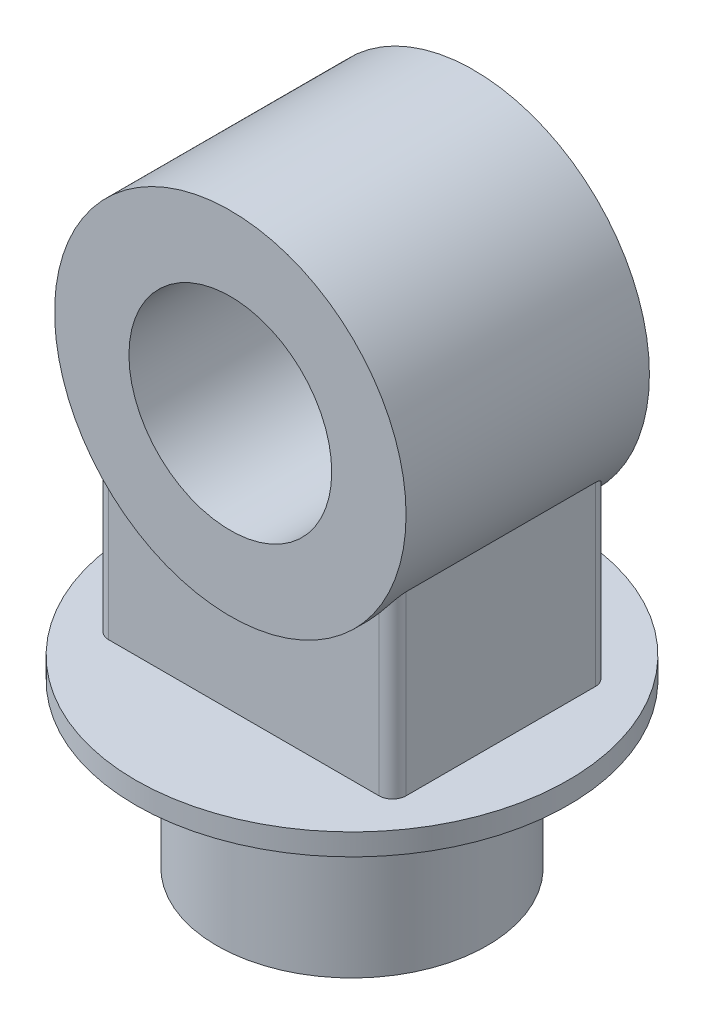
from build123d import *

# Parameters (mm, degrees)
SKETCH2_R                = 100
BOSS_EXTRUDE1_DEPTH      = 120
SKETCH3_R                = 160
BOSS_EXTRUDE2_DEPTH      = 16
SKETCH4_R                = 130
SKETCH4_R_2              = 75
BOSS_EXTRUDE7_DEPTH      = 90
BOSS_EXTRUDE8_REACH      = 402.125
BOSS_EXTRUDE8_END_RADIUS = 130
SKETCH6_W                = 220
SKETCH6_H                = 160
FILLET1_R                = 10


with BuildPart() as part:
    # Sketch2 → Boss-Extrude1 (new body)
    with BuildSketch(Plane(origin=(0, 0, 0), x_dir=(1, 0, 0), z_dir=(0, 1, 0))):
        with Locations(Location((0, 0, 0), (0, 0, 270))):
            Circle(SKETCH2_R)
    extrude(amount=BOSS_EXTRUDE1_DEPTH)

    # Sketch3 → Boss-Extrude2 (add)
    with BuildSketch(Plane(origin=(0, 120, 0), x_dir=(1, 0, 0), z_dir=(0, 1, 0))):
        with Locations(Location((0, 0, 0), (0, 0, 270))):
            Circle(SKETCH3_R)
    extrude(amount=BOSS_EXTRUDE2_DEPTH)



with BuildPart() as body_2:
    # Sketch4 → Boss-Extrude7 (new, symmetric)
    with BuildSketch(Plane.XY):
        with Locations(Location((0, 336, 0), (0, 0, 180))):
            Circle(SKETCH4_R)
        with Locations(Location((0, 336, 0), (0, 0, 180))):
            Circle(SKETCH4_R_2, mode=Mode.SUBTRACT)
    extrude(amount=BOSS_EXTRUDE7_DEPTH, both=True)


with BuildPart() as part_1:
    add(part.part)

    add(body_2.part)  # Boss-Extrude8 merges body 2
    # Boss-Extrude8: up to this cylinder (the profile starts outside it)
    boss_extrude8_end = Plane(origin=(0, 336, 0), z_dir=(0, 0, -1)) * Cylinder(BOSS_EXTRUDE8_END_RADIUS, 1065.25, mode=Mode.PRIVATE)
    # Sketch6 → Boss-Extrude8 (add, up to the surface)
    with BuildSketch(Plane(origin=(0, 136, 0), x_dir=(1, 0, 0), z_dir=(0, 1, 0)), mode=Mode.PRIVATE) as boss_extrude8_sk1:
        Rectangle(SKETCH6_W, SKETCH6_H)
    boss_extrude8_tool1 = extrude(boss_extrude8_sk1.sketch, amount=BOSS_EXTRUDE8_REACH, mode=Mode.PRIVATE) - boss_extrude8_end
    add(boss_extrude8_tool1.solids().sort_by_distance((0, 136, 0))[0])

    # Fillet1
    fillet1_edges = [part_1.edges().sort_by_distance(p)[0] for p in [
        (110, 201.358983849, -80),
        (110, 201.358983849, 80),
        (-110, 201.358983849, -80),
        (-110, 201.358983849, 80),
    ]]
    fillet(fillet1_edges, radius=FILLET1_R)


solid = part_1.part
